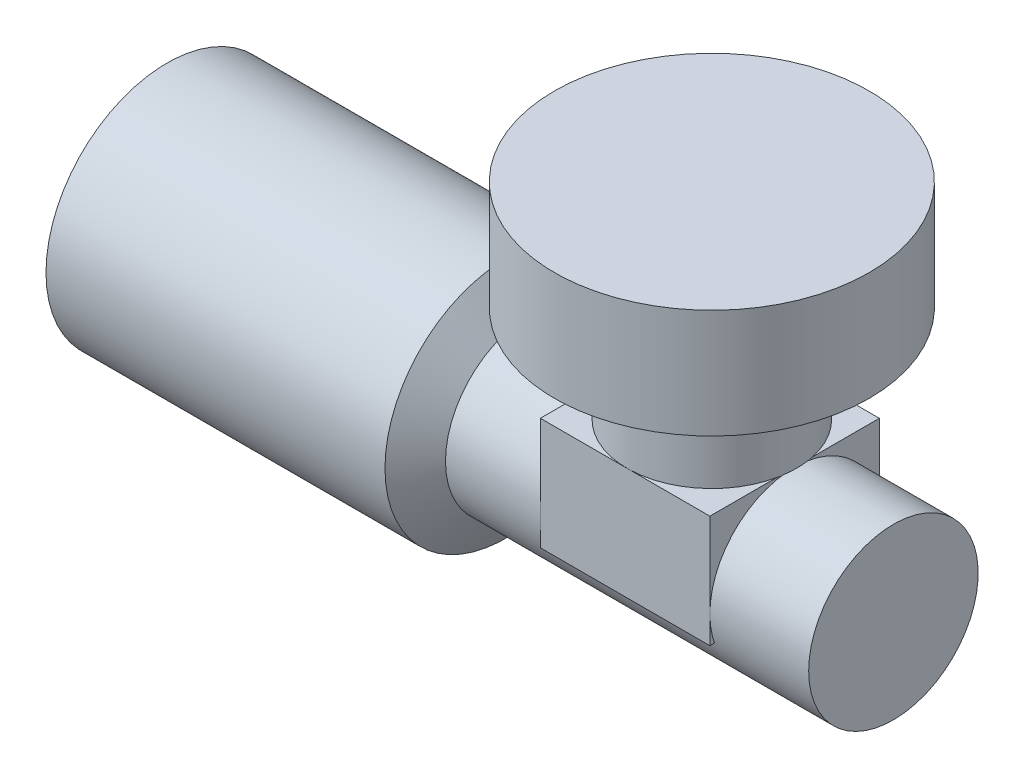
from build123d import *

# Parameters (mm, degrees)
BOSS_EXTRUDE2_START = 13.5
SKETCH5_W           = 14
SKETCH5_H           = 9.269178055
BOSS_EXTRUDE2_DEPTH = 7


with BuildPart() as part:
    # Sketch1 → Revolve1 (revolve)
    with BuildSketch(Plane(origin=(0, 0, 0), x_dir=(1, 0, 0), z_dir=(0, 1, 0))):
        Polygon((-31.337087529, 10), (-3.337087529, 10), (-1.337087529, 7), (28.662912471, 7), (28.662912471, 0), (-31.337087529, 0), align=None)
    revolve(axis=Axis((-36.380417391, 0, 0), (1, 0, 0)))


with BuildPart() as body_2:
    # Sketch4 → Revolve2 (revolve)
    with BuildSketch(Plane.XY):
        Polygon((6.662912471, 7), (6.662912471, 13), (0.662912471, 15), (0.662912471, 24), (13.662912471, 24), (13.662912471, 7), align=None)
    revolve(axis=Axis((13.662912471, 24, 0), (0, -1, 0)))


with BuildPart() as body_3:
    # Sketch5 → Boss-Extrude2 (new body, symmetric)
    with BuildSketch(Plane(origin=(0, 0, 0), x_dir=(0, 0, -1), z_dir=(1, 0, 0)).offset(BOSS_EXTRUDE2_START)):
        with Locations((0, 2.365410972)):
            Rectangle(SKETCH5_W, SKETCH5_H)
    extrude(amount=BOSS_EXTRUDE2_DEPTH, both=True)


solid = Compound([part.part, body_2.part, body_3.part])
